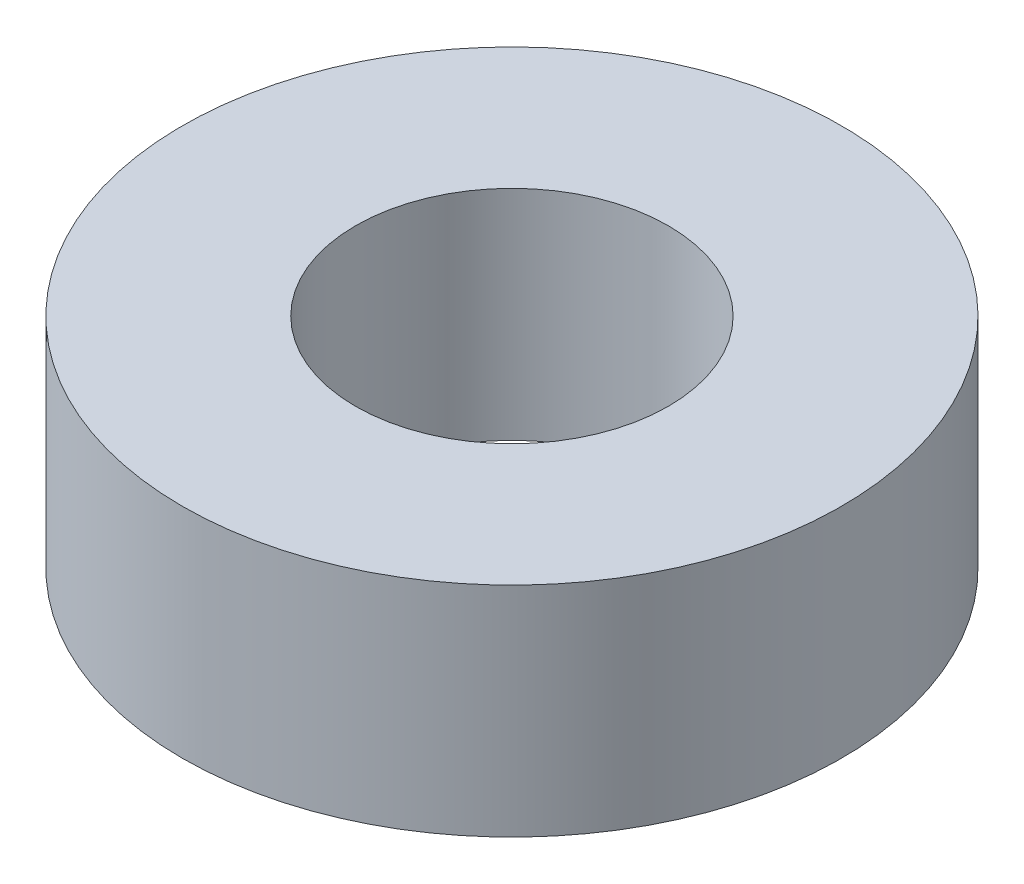
from build123d import *

# Parameters (mm, degrees)
CROQUIS2_R              = 22.65
CROQUIS2_R_2            = 10.75
SALIENTE_EXTRUIR1_DEPTH = 15


with BuildPart() as part:
    # Croquis2 → Saliente-Extruir1 (new body)
    with BuildSketch(Plane(origin=(0, 0, 0), x_dir=(1, 0, 0), z_dir=(0, 1, 0))):
        Circle(CROQUIS2_R)
        Circle(CROQUIS2_R_2, mode=Mode.SUBTRACT)
    extrude(amount=SALIENTE_EXTRUIR1_DEPTH)


solid = part.part
